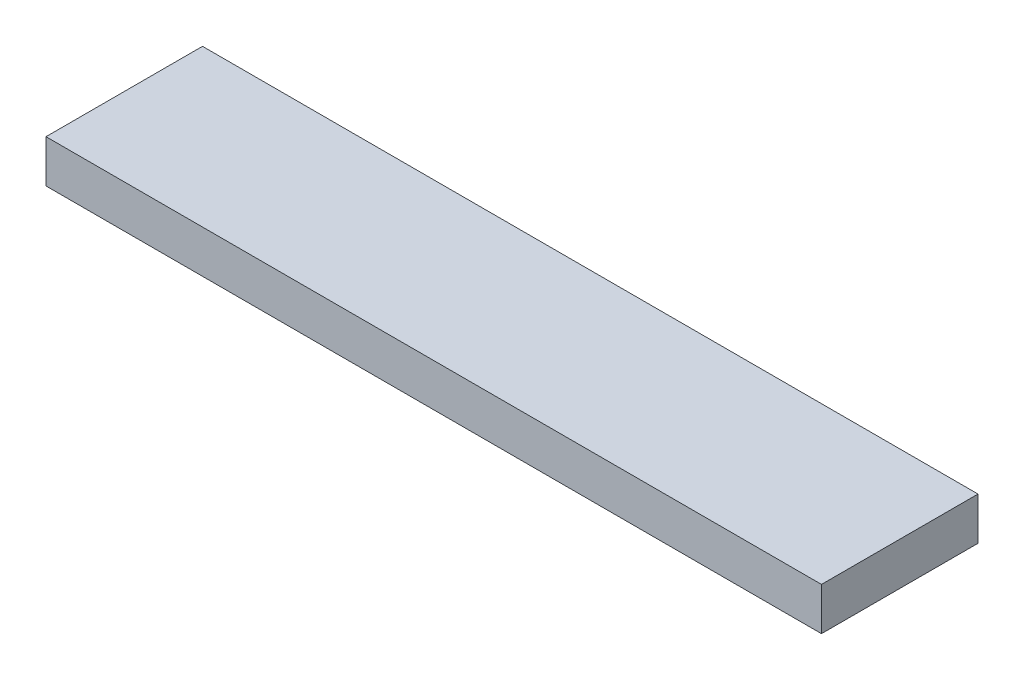
from build123d import *

# Parameters (mm, degrees)
SKETCH1_W           = 692.15
SKETCH1_H           = 139.7
BOSS_EXTRUDE1_DEPTH = 38.1


with BuildPart() as part:
    # Sketch1 → Boss-Extrude1 (new body)
    with BuildSketch(Plane(origin=(0, 0, 0), x_dir=(1, 0, 0), z_dir=(0, 1, 0))):
        with Locations((346.075, 69.85)):
            Rectangle(SKETCH1_W, SKETCH1_H)
    extrude(amount=BOSS_EXTRUDE1_DEPTH)


solid = part.part
